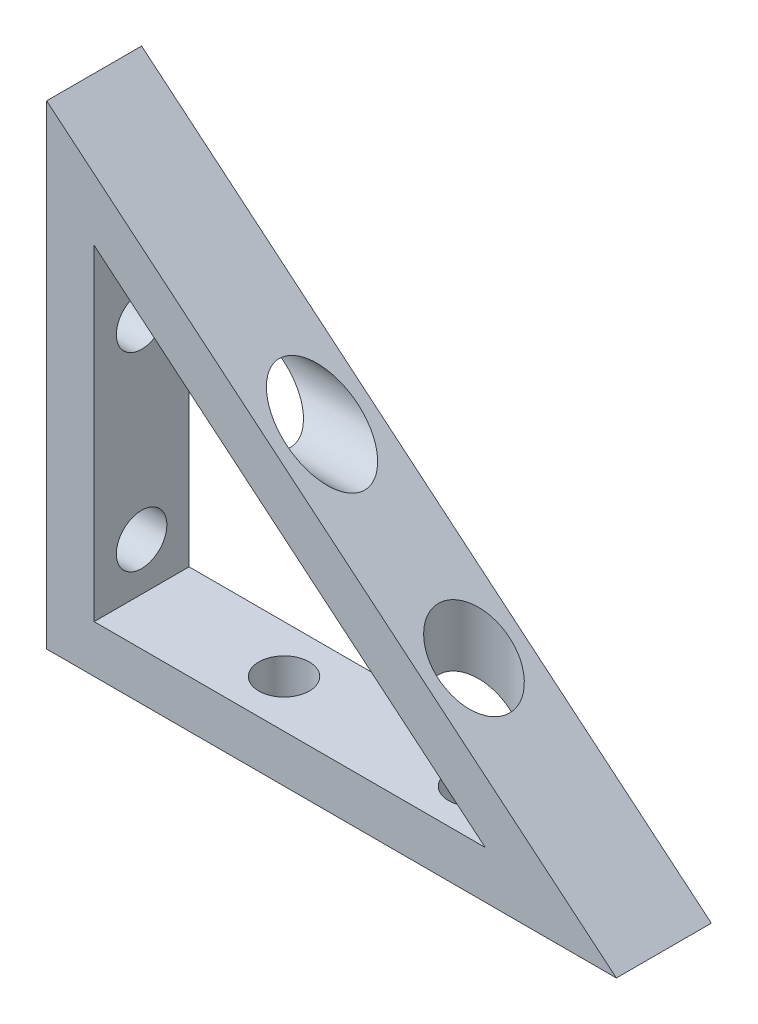
from build123d import *

# Parameters (mm, degrees)
BOSS_EXTRUDE1_DEPTH              = 12.7
F_1_4_CLEARANCE_HOLE1_D          = 6.7564
F_1_4_CLEARANCE_HOLE1_DEPTH      = 6.35
SKETCH4_W                        = 3.3782
SKETCH4_H                        = 6.35
F_1_4_CLEARANCE_HOLE2_AT_2_COUNT = 2
F_1_4_CLEARANCE_HOLE2_AT_2_PITCH = 25.4
SKETCH6_R                        = 4.7625
CUT_EXTRUDE1_DEPTH               = 70.85
SKETCH7_R                        = 4.7625
CUT_EXTRUDE2_DEPTH               = 58.15


with BuildPart() as part:
    # Sketch1 → Boss-Extrude1 (new body)
    with BuildSketch(Plane.XY):
        Polygon((0, 0), (0, 63.5), (76.2, 0), align=None)
        Polygon((6.35, 49.94248576), (6.35, 6.35), (58.660982912, 6.35), align=None, mode=Mode.SUBTRACT)
    extrude(amount=BOSS_EXTRUDE1_DEPTH)

    # 1/4 Clearance Hole1
    with Locations(Plane(origin=(6.35, 0, 0), x_dir=(0, 0, -1), z_dir=(1, 0, 0))):
        with Locations((-6.35, 12.7), (-6.35, 38.1)):
            Hole(F_1_4_CLEARANCE_HOLE1_D / 2, depth=F_1_4_CLEARANCE_HOLE1_DEPTH)

    # Sketch4 → 1/4 Clearance Hole2 (revolve, cut)
    with BuildSketch(Plane(origin=(25.4, 6.35, 6.35), x_dir=(0, 0, 1), z_dir=(1, 0, 0))):
        with Locations((1.6891, 3.175)):
            Rectangle(SKETCH4_W, SKETCH4_H)
    f_1_4_clearance_hole2 = revolve(axis=Axis((25.4, 12.7, 6.35), (0, -1, 0)), mode=Mode.SUBTRACT)

    # 1/4 Clearance Hole2 at 2: 1/4 Clearance Hole2 ×2
    with Locations(*[(i * F_1_4_CLEARANCE_HOLE2_AT_2_PITCH, 0, 0) for i in range(1, F_1_4_CLEARANCE_HOLE2_AT_2_COUNT)]):
        add(f_1_4_clearance_hole2, mode=Mode.SUBTRACT)

    # Sketch6 → Cut-Extrude1 (cut, through all)
    with BuildSketch(Plane(origin=(6.35, 0, 0), x_dir=(0, 0, -1), z_dir=(1, 0, 0))):
        with Locations((-6.35, 38.1)):
            Circle(SKETCH6_R)
    extrude(amount=CUT_EXTRUDE1_DEPTH, mode=Mode.SUBTRACT)

    # Sketch7 → Cut-Extrude2 (cut, through all)
    with BuildSketch(Plane(origin=(0, 6.35, 0), x_dir=(1, 0, 0), z_dir=(0, 1, 0))):
        with Locations((50.8, -6.35)):
            Circle(SKETCH7_R)
    extrude(amount=CUT_EXTRUDE2_DEPTH, mode=Mode.SUBTRACT)


solid = part.part
